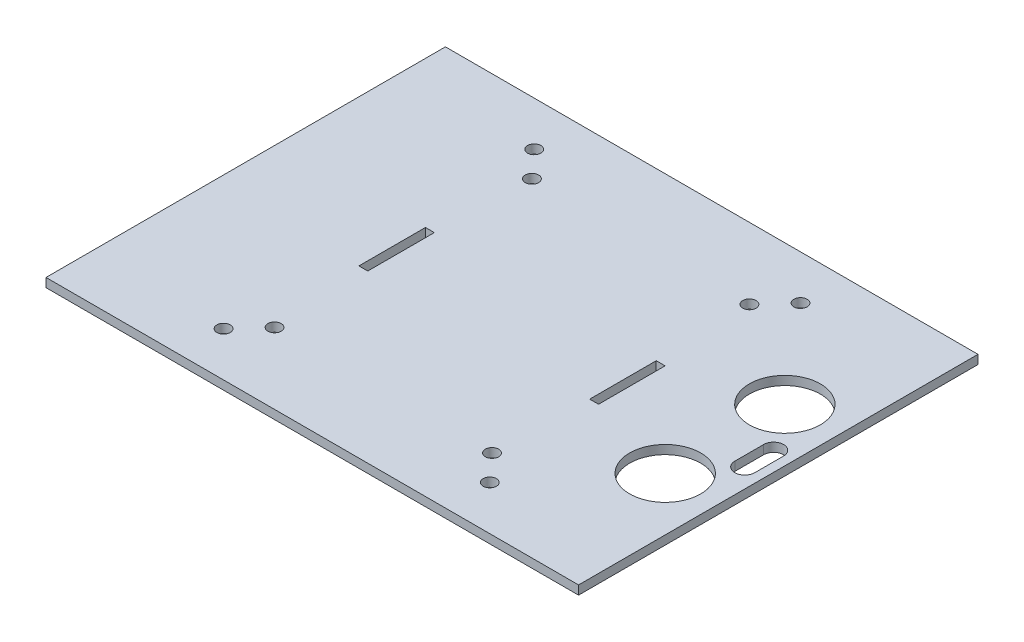
from build123d import *

# Parameters (mm, degrees)
SKETCH_1_W          = 120
SKETCH_1_H          = 90
SKETCH_1_R          = 1.5
SKETCH_1_W_2        = 2
SKETCH_1_H_2        = 15
EXTRUDE_1_DEPTH     = 2
SKETCH_2_R          = 8
CUT_EXTRUDE_1_DEPTH = 3


with BuildPart() as part:
    # 草圖1 → 填料-伸長1 (new body)
    with BuildSketch(Plane(origin=(0, 0, 0), x_dir=(1, 0, 0), z_dir=(0, 1, 0))):
        Rectangle(SKETCH_1_W, SKETCH_1_H)
        with Locations((-30, 35)):
            Circle(SKETCH_1_R, mode=Mode.SUBTRACT)
        with Locations((30, 35)):
            Circle(SKETCH_1_R, mode=Mode.SUBTRACT)
        with Locations((30, -35)):
            Circle(SKETCH_1_R, mode=Mode.SUBTRACT)
        with Locations((-30, -35)):
            Circle(SKETCH_1_R, mode=Mode.SUBTRACT)
        with Locations((24.5, 29)):
            Circle(SKETCH_1_R, mode=Mode.SUBTRACT)
        with Locations((24.5, -29)):
            Circle(SKETCH_1_R, mode=Mode.SUBTRACT)
        with Locations((-24.5, 29)):
            Circle(SKETCH_1_R, mode=Mode.SUBTRACT)
        with Locations((-24.5, -29)):
            Circle(SKETCH_1_R, mode=Mode.SUBTRACT)
        with Locations((-26, 0)):
            Rectangle(SKETCH_1_W_2, SKETCH_1_H_2, mode=Mode.SUBTRACT)
        with Locations((26, 0)):
            Rectangle(SKETCH_1_W_2, SKETCH_1_H_2, mode=Mode.SUBTRACT)
    extrude(amount=EXTRUDE_1_DEPTH)

    # 草圖2 → 除料-伸長1 (cut, through all)
    with BuildSketch(Plane(origin=(0, 2, 0), x_dir=(1, 0, 0), z_dir=(0, 1, 0))):
        with Locations((48, 13.48)):
            Circle(SKETCH_2_R)
        with Locations((48, -13.48)):
            Circle(SKETCH_2_R)
        with BuildLine():
            Line((53.45, -3.25), (53.45, 3.25))
            ThreePointArc((53.45, 3.25), (55.7, 5.5), (57.95, 3.25))
            Line((57.95, 3.25), (57.95, -3.25))
            ThreePointArc((57.95, -3.25), (55.7, -5.5), (53.45, -3.25))
        make_face()
    extrude(amount=-CUT_EXTRUDE_1_DEPTH, mode=Mode.SUBTRACT)


solid = part.part
